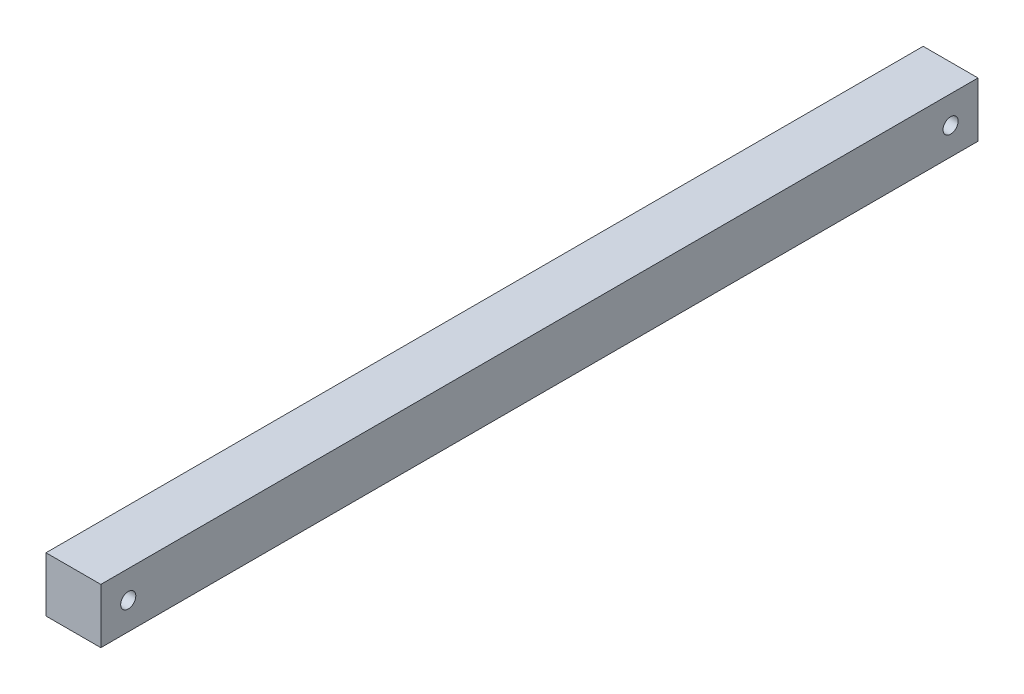
from build123d import *

# Parameters (mm, degrees)
SKETCH1_W           = 25.4
SKETCH1_H           = 25.4
BOSS_EXTRUDE1_DEPTH = 406.4
SKETCH10_R          = 3.5
CUT_EXTRUDE6_DEPTH  = 26.4


with BuildPart() as part:
    # Sketch1 → Boss-Extrude1 (new body)
    with BuildSketch(Plane.XY):
        Rectangle(SKETCH1_W, SKETCH1_H)
    extrude(amount=BOSS_EXTRUDE1_DEPTH)

    # Sketch10 → Cut-Extrude6 (cut, through all)
    with BuildSketch(Plane.ZY.offset(12.7)):
        with Locations((393.7, 0)):
            Circle(SKETCH10_R)
        with Locations((12.7, 0)):
            Circle(SKETCH10_R)
    extrude(amount=-CUT_EXTRUDE6_DEPTH, mode=Mode.SUBTRACT)


solid = part.part
